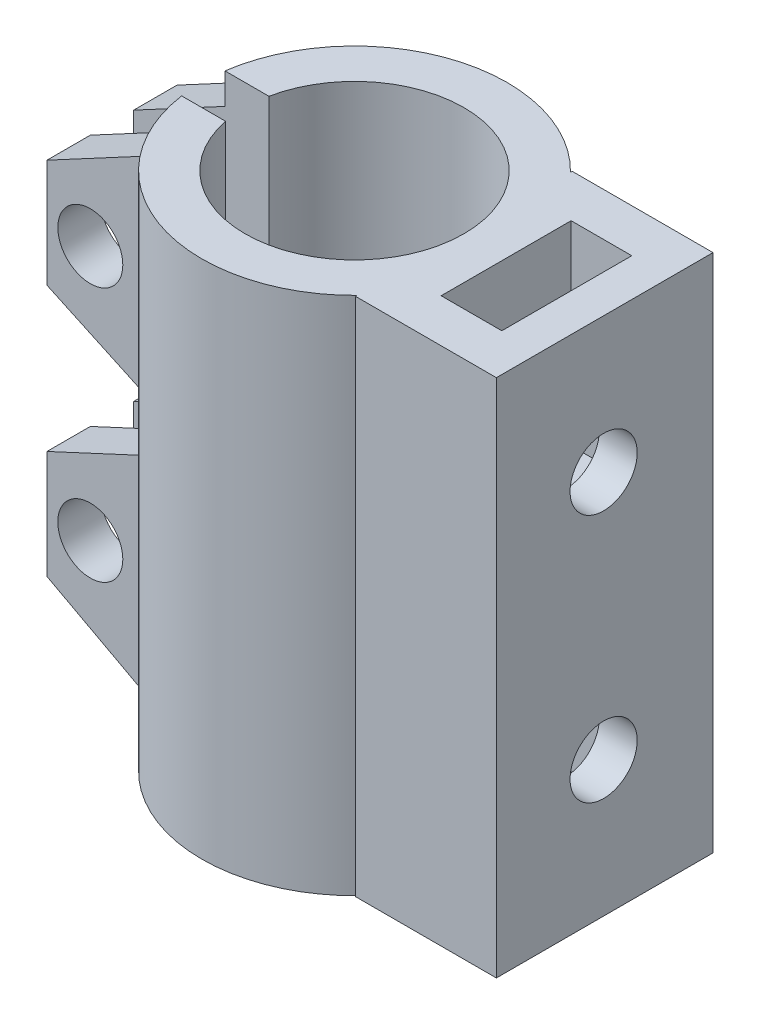
from build123d import *

# Parameters (mm, degrees)
SKETCH2_W               = 6.825797408
SKETCH2_H               = 2
CUT_EXTRUDE1_DEPTH      = 25
SKETCH3_R               = 1.5
BOSS_EXTRUDE1_DEPTH     = 2
SKETCH4_W               = 6.5
SKETCH4_H               = 10
BOSS_EXTRUDE2_DEPTH     = 24
SKETCH5_W               = 2.8
SKETCH5_H               = 6
CUT_EXTRUDE2_DEPTH      = 9
SKETCH6_R               = 1.55
CUT_EXTRUDE3_DEPTH      = 10
MIRROR4_COPY_1_SKETCH_R = 1.5
MIRROR4_COPY_1_DEPTH    = 2


with BuildPart() as part:
    # Sketch1 → Revolve1 (revolve)
    with BuildSketch(Plane.XY):
        Polygon((-2.660447761, -21.041604478), (-7.160447761, -21.041604478), (-7.160447761, 2.958395522), (-5.160447761, 2.958395522), (-5.160447761, -11.041604478), (-2.660447761, -11.041604478), align=None)
    revolve(axis=Axis((-0.110447761, 2.958395522, 0), (0, -1, 0)))

    # Sketch2 → Cut-Extrude1 (cut, through all)
    with BuildSketch(Plane(origin=(0, 2.958395522, 0), x_dir=(1, 0, 0), z_dir=(0, 1, 0))):
        with Locations((-5.160447761, 0)):
            Rectangle(SKETCH2_W, SKETCH2_H)
    extrude(amount=-CUT_EXTRUDE1_DEPTH, mode=Mode.SUBTRACT)

    # Sketch3 → Boss-Extrude1 (add)
    with BuildSketch(Plane.XY.offset(-1)):
        Polygon((-6.305854072, 1.958395522), (-11.305854072, -0.719474979), (-11.305854072, -5.719474979), (-6.305854072, -8.041604478), align=None)
        with Locations((-9.305854072, -3.157710953)):
            Circle(SKETCH3_R, mode=Mode.SUBTRACT)
    boss_extrude1 = extrude(amount=-BOSS_EXTRUDE1_DEPTH)

    # Mirror1: Boss-Extrude1 across plane
    add(boss_extrude1.mirror(Plane.XY))

    # Sketch4 → Boss-Extrude2 (add, through all)
    with BuildSketch(Plane(origin=(0, 2.958395522, 0), x_dir=(1, 0, 0), z_dir=(0, 1, 0))):
        with Locations((8.189552239, 0)):
            Rectangle(SKETCH4_W, SKETCH4_H)
    extrude(amount=-BOSS_EXTRUDE2_DEPTH)

    # Sketch5 → Cut-Extrude2 (cut)
    with BuildSketch(Plane(origin=(0, 2.958395522, 0), x_dir=(1, 0, 0), z_dir=(0, 1, 0))):
        with Locations((8.289552239, 0)):
            Rectangle(SKETCH5_W, SKETCH5_H)
    cut_extrude2 = extrude(amount=-CUT_EXTRUDE2_DEPTH, mode=Mode.SUBTRACT)

    # Mirror2: Cut-Extrude2 across plane
    add(cut_extrude2.mirror(Plane.ZX.offset(-9.041604478)), mode=Mode.SUBTRACT)

    # Sketch6 → Cut-Extrude3 (cut)
    with BuildSketch(Plane(origin=(11.439552239, 0, 0), x_dir=(0, 0, -1), z_dir=(1, 0, 0))):
        with Locations((-0.05, -3.291604478)):
            Circle(SKETCH6_R)
    cut_extrude3 = extrude(amount=-CUT_EXTRUDE3_DEPTH, mode=Mode.SUBTRACT)

    # Mirror3: Cut-Extrude3 across plane
    add(cut_extrude3.mirror(Plane.ZX.offset(-9.041604478)), mode=Mode.SUBTRACT)

    # Mirror4: Boss-Extrude1 across plane
    add(boss_extrude1.mirror(Plane.ZX.offset(-9.041604478)))

    # Mirror4 copy 1 sketch → Mirror4 copy 1 (add)
    with BuildSketch(Plane(origin=(0, -18.083208955, 1), x_dir=(1, 0, 0), z_dir=(0, 0, -1))):
        Polygon((-6.305854072, 1.958395522), (-11.305854072, -0.719474979), (-11.305854072, -5.719474979), (-6.305854072, -8.041604478), align=None)
        with Locations((-9.305854072, -3.157710953)):
            Circle(MIRROR4_COPY_1_SKETCH_R, mode=Mode.SUBTRACT)
    extrude(amount=-MIRROR4_COPY_1_DEPTH)


solid = part.part
